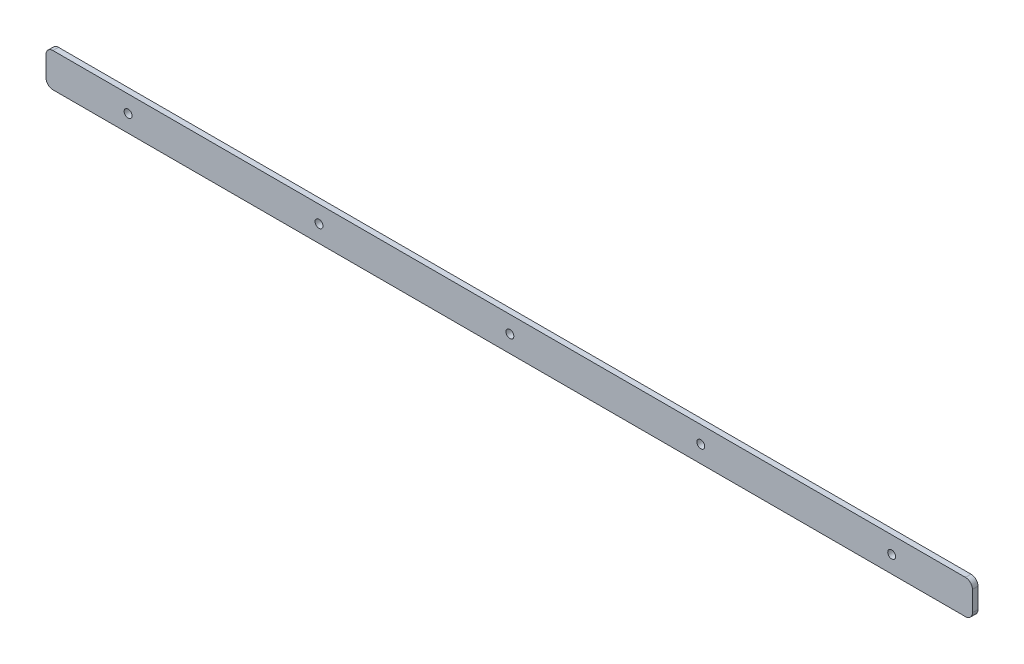
from build123d import *

# Parameters (mm, degrees)
SKETCH1_W             = 528.828
SKETCH1_H             = 19.431
BOSS_EXTRUDE1_DEPTH   = 3.175
F_8_CLEARANCE_HOLE1_D = 4.4958
FILLET1_R             = 3.96875
LPATTERN1_COUNT       = 5
LPATTERN1_PITCH       = 108.966


with BuildPart() as part:
    # Sketch1 → Boss-Extrude1 (new body)
    with BuildSketch(Plane.XY):
        with Locations((264.414, 9.7155)):
            Rectangle(SKETCH1_W, SKETCH1_H)
    extrude(amount=BOSS_EXTRUDE1_DEPTH)

    # #8 Clearance Hole1 (through all)
    with Locations(Plane.XY.offset(3.175)):
        with Locations((46.863, 9.7155)):
            f_8_clearance_hole1 = Hole(F_8_CLEARANCE_HOLE1_D / 2)

    # Fillet1
    fillet1_edges = [part.edges().sort_by_distance(p)[0] for p in [
        (0, 19.431, 1.5875),
        (528.828, 19.431, 1.5875),
        (528.828, 0, 1.5875),
        (0, 0, 1.5875),
    ]]
    fillet(fillet1_edges, radius=FILLET1_R)

    # LPattern1: #8 Clearance Hole1 ×5
    with Locations(*[(i * LPATTERN1_PITCH, 0, 0) for i in range(1, LPATTERN1_COUNT)]):
        add(f_8_clearance_hole1, mode=Mode.SUBTRACT)


solid = part.part
